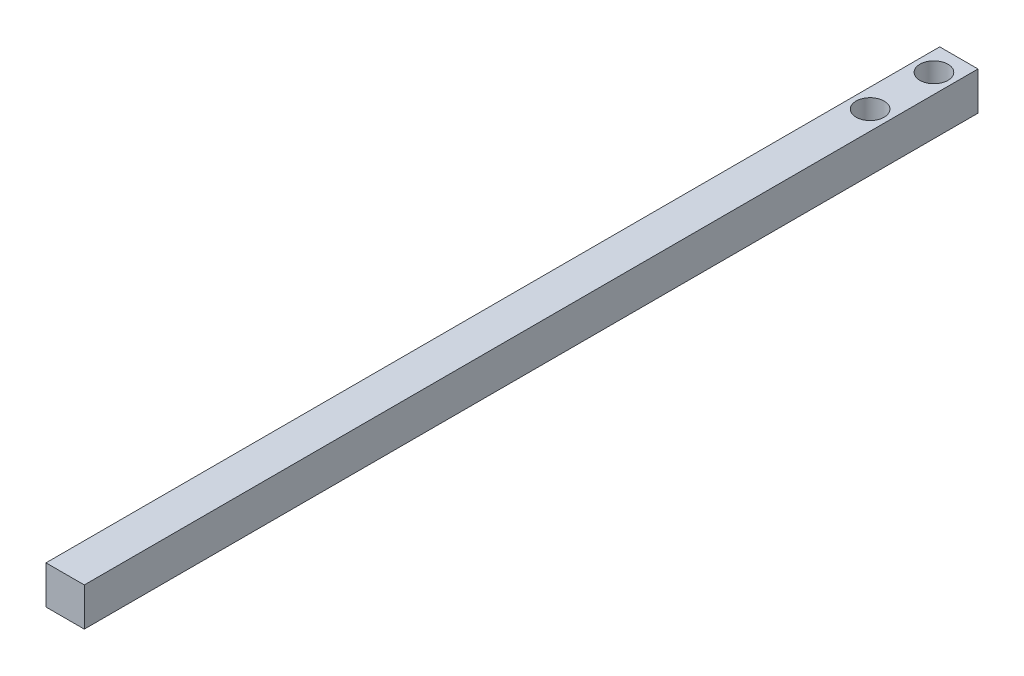
from build123d import *

# Parameters (mm, degrees)
SKETCH2_W           = 3
SKETCH2_H           = 70
BOSS_EXTRUDE2_DEPTH = 3
SKETCH4_R           = 1.1
CUT_EXTRUDE1_DEPTH  = 4


with BuildPart() as part:
    # Sketch2 → Boss-Extrude2 (new body)
    with BuildSketch(Plane(origin=(0, 0, 0), x_dir=(1, 0, 0), z_dir=(0, 1, 0))):
        with Locations((1.5, 35)):
            Rectangle(SKETCH2_W, SKETCH2_H)
    extrude(amount=BOSS_EXTRUDE2_DEPTH)

    # Sketch4 → Cut-Extrude1 (cut, through all)
    with BuildSketch(Plane(origin=(0, 3, 0), x_dir=(1, 0, 0), z_dir=(0, 1, 0))):
        with Locations((1.5, 68.047484244)):
            Circle(SKETCH4_R)
        with Locations((1.5, 63.047484244)):
            Circle(SKETCH4_R)
    extrude(amount=-CUT_EXTRUDE1_DEPTH, mode=Mode.SUBTRACT)


solid = part.part
